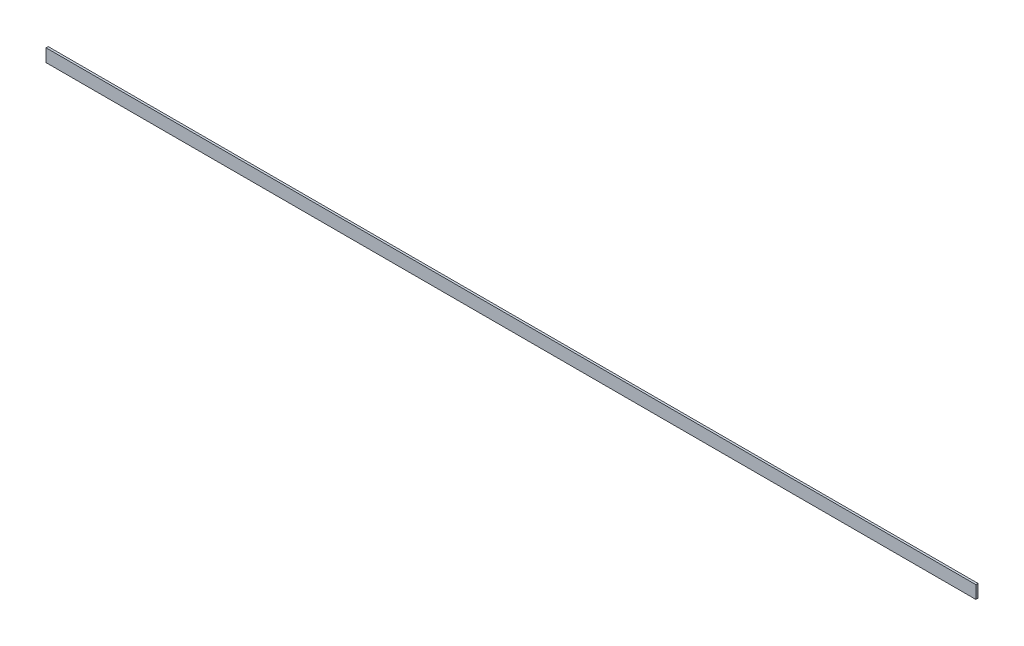
from build123d import *

# Parameters (mm, degrees)
SKETCH_1_W      = 5
SKETCH_1_H      = 30
EXTRUDE_1_DEPTH = 2170


with BuildPart() as part:
    # Эскиз1 → Бобышка-Вытянуть1 (new body)
    with BuildSketch(Plane(origin=(0, 0, 0), x_dir=(0, 0, -1), z_dir=(1, 0, 0))):
        with Locations((2.5, 15)):
            Rectangle(SKETCH_1_W, SKETCH_1_H)
    extrude(amount=EXTRUDE_1_DEPTH)


solid = part.part
